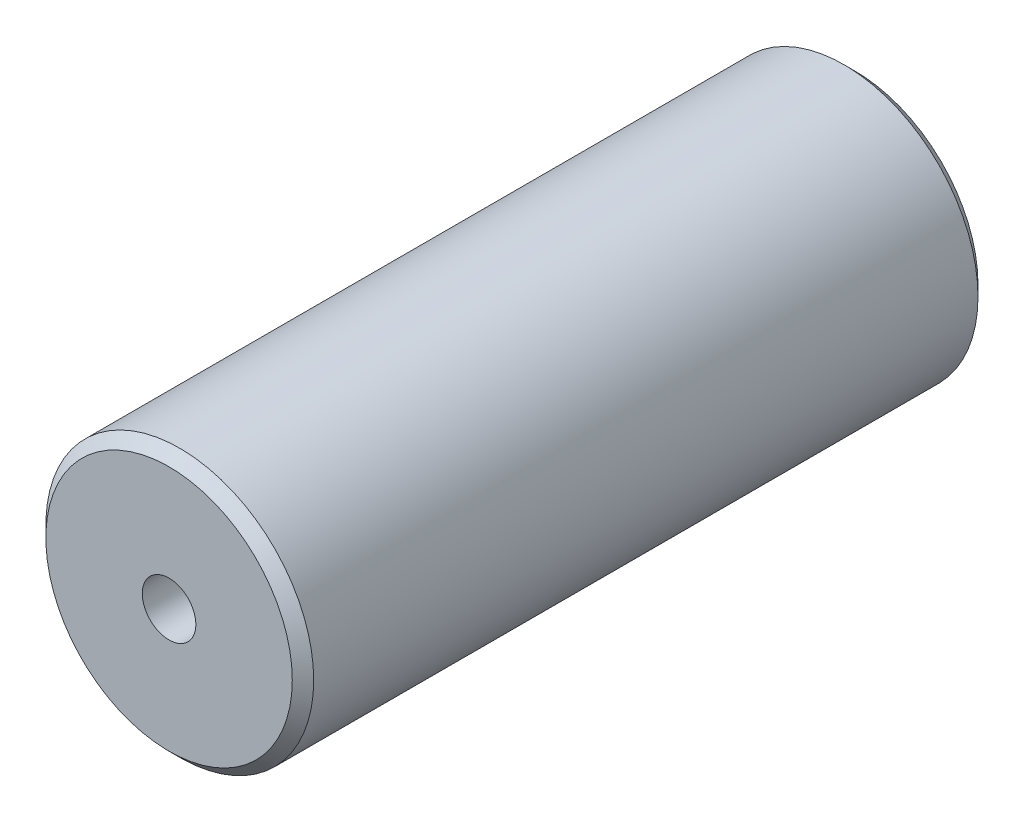
from build123d import *

# Parameters (mm, degrees)
SKETCH1_R           = 12.5
BOSS_EXTRUDE1_DEPTH = 32
CHAMFER1_SIZE       = 1


with BuildPart() as part:
    # Sketch1 → Boss-Extrude1 (new body, symmetric)
    with BuildSketch(Plane.XY):
        Circle(SKETCH1_R)
    extrude(amount=BOSS_EXTRUDE1_DEPTH, both=True)

    # Chamfer1
    chamfer1_edges = [part.edges().sort_by_distance(p)[0] for p in [
        (-12.5, 0, -32),
        (-12.5, 0, 32),
    ]]
    chamfer(chamfer1_edges, length=CHAMFER1_SIZE)

    # Sketch4 → M6 Tapped Hole1 (revolve, cut)
    with BuildSketch(Plane(origin=(0, 0, 32), x_dir=(0, -1, 0), z_dir=(1, 0, 0))):
        Polygon((0, 0), (0, 16.502151548), (2.5, 15), (2.5, 0), align=None)
    m6_tapped_hole1 = revolve(axis=Axis((0, 0, 38.35), (0, 0, -1)), mode=Mode.SUBTRACT)

    # Mirror1: M6 Tapped Hole1 across plane
    add(m6_tapped_hole1.mirror(Plane.XY), mode=Mode.SUBTRACT)


solid = part.part
